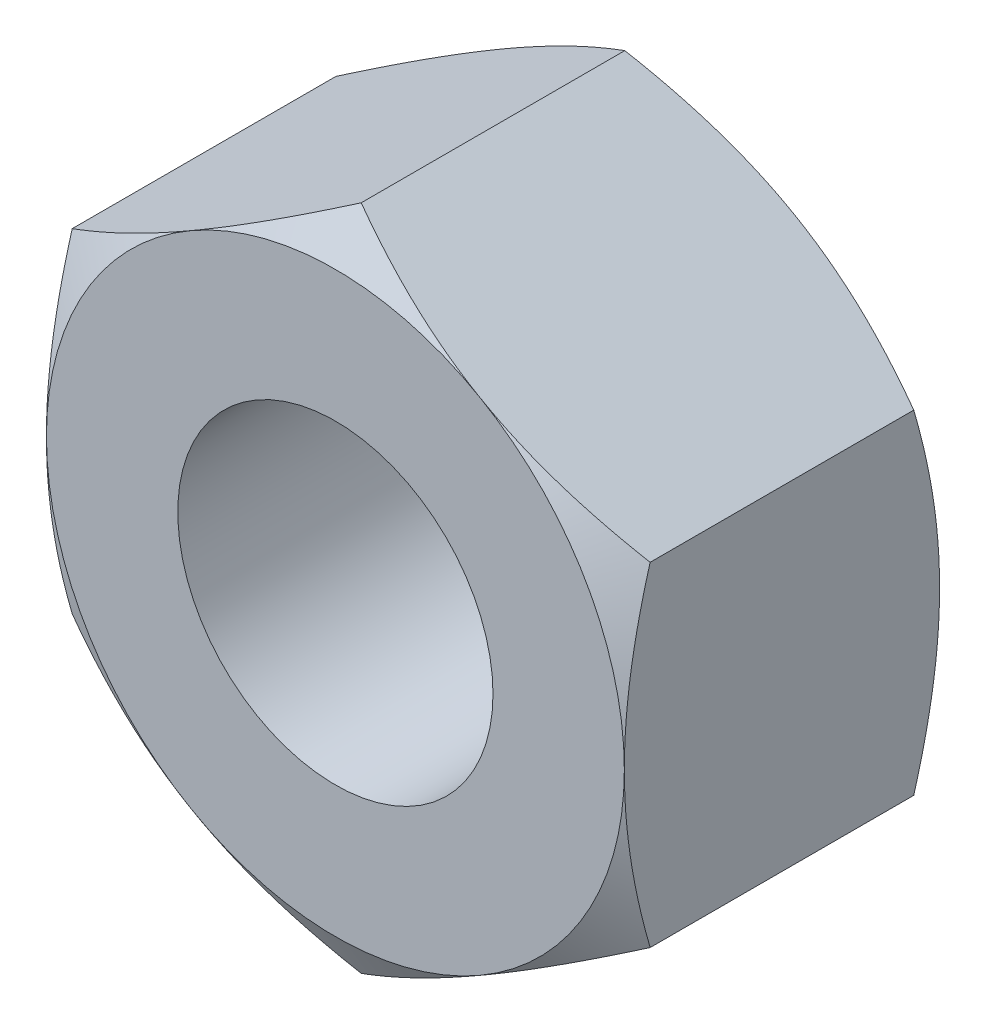
from build123d import *

# Parameters (mm, degrees)
BOSS_EXTRU_1_DEPTH      = 3
ENL_V_MAT_EXTRU_1_REACH = 5
ESQUISSE2_R             = 1.5


with BuildPart() as part:
    # Esquisse1 → Boss.-Extru.1 (new body)
    with BuildSketch(Plane.XY):
        Polygon((0, 3.175426481), (-2.75, 1.58771324), (-2.75, -1.58771324), (0, -3.175426481), (2.75, -1.58771324), (2.75, 1.58771324), align=None)
    extrude(amount=BOSS_EXTRU_1_DEPTH)

    # Esquisse2 → Enlèv. mat.-Extru.1 (cut, up to next)
    with BuildSketch(Plane.XY.offset(3), mode=Mode.PRIVATE) as enl_v_mat_extru_1_sk1:
        Circle(ESQUISSE2_R)
    enl_v_mat_extru_1_tool1 = extrude(enl_v_mat_extru_1_sk1.sketch, amount=-ENL_V_MAT_EXTRU_1_REACH, mode=Mode.PRIVATE) & part.part
    add(enl_v_mat_extru_1_tool1.solids().sort_by_distance((0, 0, 3))[0], mode=Mode.SUBTRACT)

    # Esquisse4 → Enlèvement de matière-Révolution8 (revolve, cut)
    with BuildSketch(Plane(origin=(0, 0, 0), x_dir=(1, 0, 0), z_dir=(0, 1, 0))):
        Polygon((-5.348076211, -1.5), (-1.017949192, 1), (-6.348076211, 1), (-6.348076211, -4), (-1.017949192, -4), align=None)
    revolve(axis=Axis((0, 0, 0), (0, 0, 1)), mode=Mode.SUBTRACT)


solid = part.part
